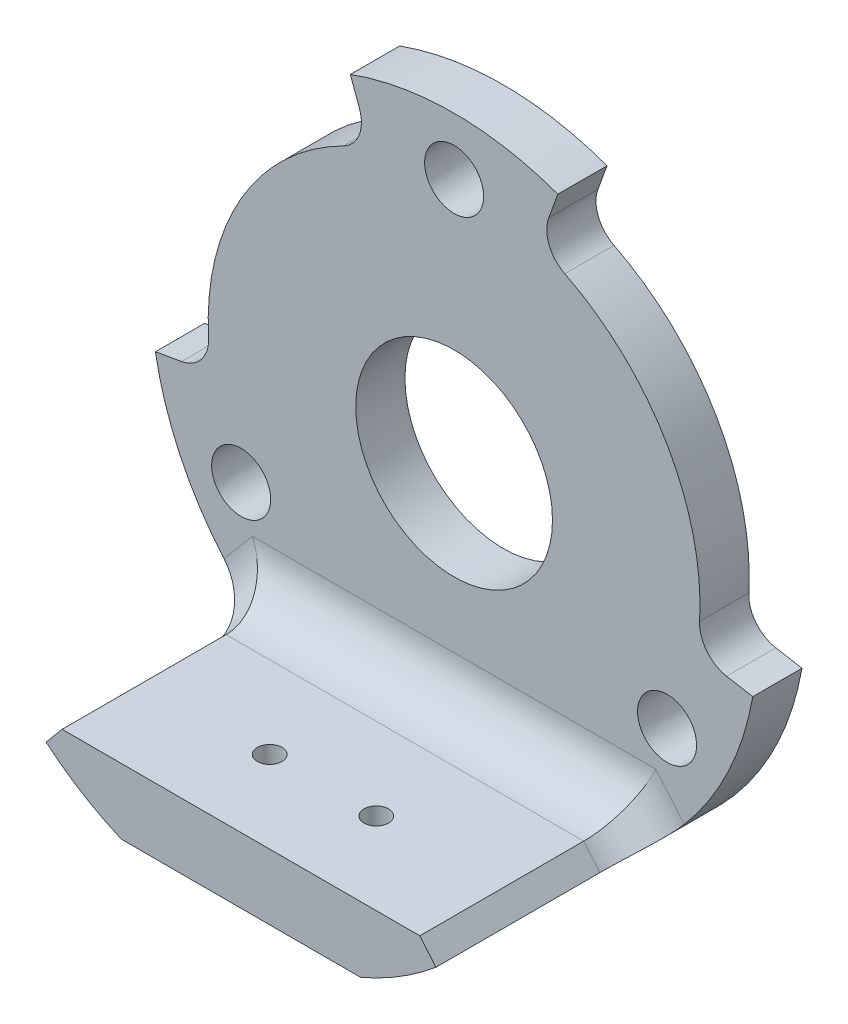
from build123d import *

# Parameters (mm, degrees)
EXTRUDE_1_DEPTH             = 16
CUT_EXTRUDE_1_DEPTH         = 13
CUT_EXTRUDE_2_DEPTH         = 17
CUT_EXTRUDE_3_DEPTH         = 17
HOLE_WIZARD_1_5_1_5_1_D     = 1.5
HOLE_WIZARD_1_5_1_5_1_DEPTH = 35.5
HOLE_WIZARD_12_0_12_1_D     = 12
HOLE_WIZARD_12_0_12_1_DEPTH = 16
HOLE_WIZARD_3_6_3_6_1_D     = 3.6
HOLE_WIZARD_3_6_3_6_1_DEPTH = 16
FILLET_1_R                  = 2
FILLET_2_R                  = 3


with BuildPart() as part:
    # 草图1 → 凸台-拉伸1 (new body)
    with BuildSketch(Plane(origin=(0, 0, 0), x_dir=(-1, 0, 0), z_dir=(0, 0, -1))):
        with BuildLine():
            Line((442.70274024, 283), (457.29725976, 283))
            ThreePointArc((457.29725976, 283), (450, 318.5), (442.70274024, 283))
        make_face()
    extrude(amount=-EXTRUDE_1_DEPTH)

    # 草图2 → 切除-拉伸1 (cut)
    with BuildSketch(Plane.XY.offset(16)):
        with BuildLine():
            Line((-461.891570779, 285.828177802), (-460.908295205, 287))
            Line((-460.908295205, 287), (-439.091704795, 287))
            Line((-439.091704795, 287), (-438.108429221, 285.828177802))
            ThreePointArc((-438.108429221, 285.828177802), (-450, 318.5), (-461.891570779, 285.828177802))
        make_face()
    extrude(amount=-CUT_EXTRUDE_1_DEPTH, mode=Mode.SUBTRACT)

    # 草图3 → 切除-拉伸2 (cut, through all)
    with BuildSketch(Plane(origin=(0, 0, 0), x_dir=(-1, 0, 0), z_dir=(0, 0, -1))):
        with BuildLine():
            Line((431.781056569, 296.787508713), (435.227883705, 297.395277335))
            ThreePointArc((435.227883705, 297.395277335), (437.009618943, 307.5), (444.86969785, 314.095389312))
            Line((444.86969785, 314.095389312), (443.672627348, 317.384313485))
            ThreePointArc((443.672627348, 317.384313485), (433.97853003, 309.25), (431.781056569, 296.787508713))
        make_face()
    extrude(amount=-CUT_EXTRUDE_2_DEPTH, mode=Mode.SUBTRACT)

    # 草图4 → 切除-拉伸3 (cut, through all)
    with BuildSketch(Plane(origin=(0, 0, 0), x_dir=(-1, 0, 0), z_dir=(0, 0, -1))):
        with BuildLine():
            Line((456.327372652, 317.384313485), (455.13030215, 314.095389312))
            ThreePointArc((455.13030215, 314.095389312), (462.990381057, 307.5), (464.772116295, 297.395277335))
            Line((464.772116295, 297.395277335), (468.218943431, 296.787508713))
            ThreePointArc((468.218943431, 296.787508713), (466.02146997, 309.25), (456.327372652, 317.384313485))
        make_face()
    extrude(amount=-CUT_EXTRUDE_3_DEPTH, mode=Mode.SUBTRACT)

    # Ø1.5 (1.5) 直径孔1
    with Locations(Plane(origin=(0, 283, 0), x_dir=(-1, 0, 0), z_dir=(0, -1, 0))):
        with Locations((446.75, -11), (453.25, -11)):
            Hole(HOLE_WIZARD_1_5_1_5_1_D / 2, depth=HOLE_WIZARD_1_5_1_5_1_DEPTH)

    # Ø12.0 (12) 直径孔1
    with Locations(Plane(origin=(0, 0, 0), x_dir=(-1, 0, 0), z_dir=(0, 0, -1))):
        with Locations((450, 300)):
            Hole(HOLE_WIZARD_12_0_12_1_D / 2, depth=HOLE_WIZARD_12_0_12_1_DEPTH)

    # Ø3.6 (3.6) 直径孔1
    with Locations(Plane(origin=(0, 0, 0), x_dir=(-1, 0, 0), z_dir=(0, 0, -1))):
        with Locations((437.009618943, 292.5), (450, 315), (462.990381057, 292.5)):
            Hole(HOLE_WIZARD_3_6_3_6_1_D / 2, depth=HOLE_WIZARD_3_6_3_6_1_DEPTH)

    # 圆角1
    fillet_1_edges = [part.edges().sort_by_distance(p)[0] for p in [
        (-444.86969785, 314.095389312, 1.5),
        (-435.227883705, 297.395277335, 1.5),
        (-464.772116295, 297.395277335, 1.5),
        (-455.13030215, 314.095389312, 1.5),
    ]]
    fillet(fillet_1_edges, radius=FILLET_1_R)

    # 圆角2
    fillet_2_edges = [part.edges().sort_by_distance(p)[0] for p in [
        (-438.600067008, 286.414088901, 3),
        (-450, 287, 3),
        (-461.399932992, 286.414088901, 3),
    ]]
    fillet(fillet_2_edges, radius=FILLET_2_R)


solid = part.part
